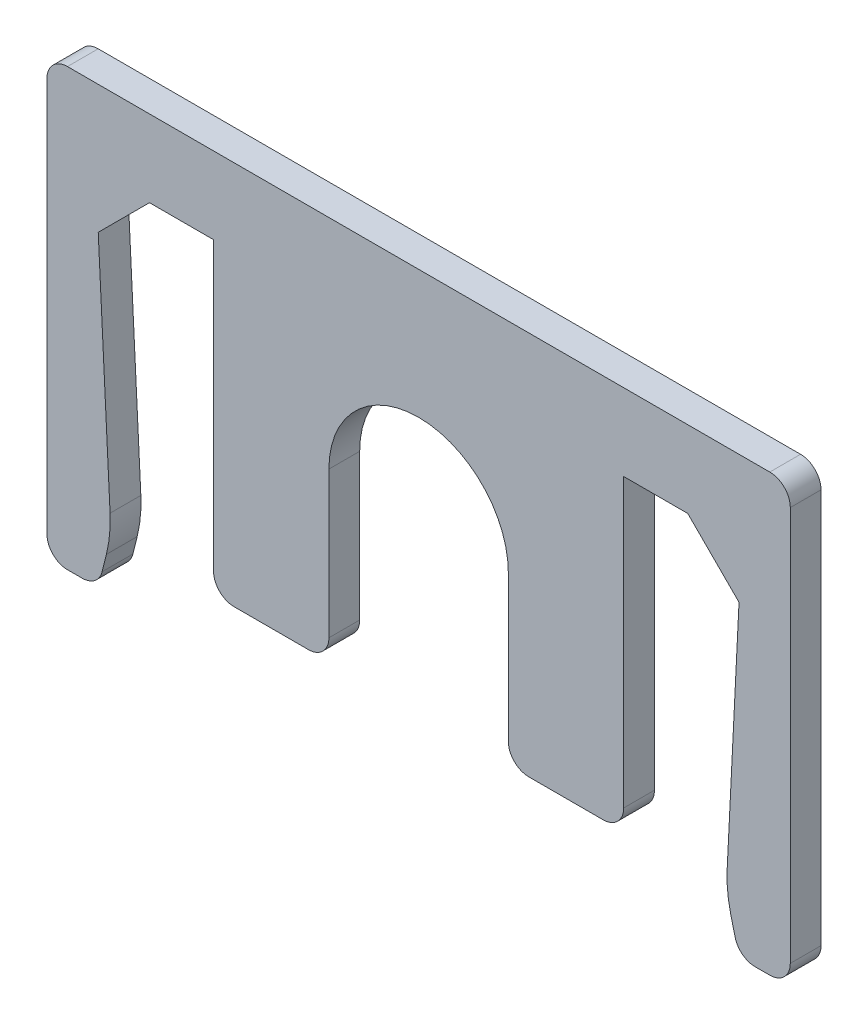
from build123d import *

# Parameters (mm, degrees)
BOSS_EXTRUDE1_DEPTH = 1.2
FILLET1_R           = 5
FILLET2_R           = 0.8


with BuildPart() as part:
    # Sketch1 → Boss-Extrude1 (new body)
    with BuildSketch(Plane.XY):
        with BuildLine():
            Line((-10.5, 0), (-12.5, -2))
            Line((-12.5, -2), (-12, -12))
            Line((-12, -12), (-12.5, -14))
            Line((-12.5, -14), (-14.5, -14))
            Line((-14.5, -14), (-14.5, 3))
            Line((-14.5, 3), (-12.5, 3))
            Line((-12.5, 3), (12.5, 3))
            Line((12.5, 3), (14.5, 3))
            Line((14.5, 3), (14.5, -14))
            Line((14.5, -14), (12.5, -14))
            Line((12.5, -14), (12, -12))
            Line((12, -12), (12.5, -2))
            Line((12.5, -2), (10.5, 0))
            Line((10.5, 0), (8, 0))
            Line((8, 0), (8, -12))
            Line((8, -12), (3.5, -12))
            Line((3.5, -12), (3.5, -5.5))
            ThreePointArc((3.5, -5.5), (0, -2), (-3.5, -5.5))
            Line((-3.5, -5.5), (-3.5, -12))
            Line((-3.5, -12), (-8, -12))
            Line((-8, -12), (-8, 0))
            Line((-8, 0), (-10.5, 0))
        make_face()
    extrude(amount=BOSS_EXTRUDE1_DEPTH)

    # Fillet1
    fillet1_edges = [part.edges().sort_by_distance(p)[0] for p in [
        (-12, -12, 0.6),
        (12, -12, 0.6),
    ]]
    fillet(fillet1_edges, radius=FILLET1_R)

    # Fillet2
    fillet2_edges = [part.edges().sort_by_distance(p)[0] for p in [
        (-12.5, -14, 0.6),
        (-14.5, -14, 0.6),
        (-14.5, 3, 0.6),
        (14.5, 3, 0.6),
        (14.5, -14, 0.6),
        (12.5, -14, 0.6),
        (8, -12, 0.6),
        (3.5, -12, 0.6),
        (-3.5, -12, 0.6),
        (-8, -12, 0.6),
    ]]
    fillet(fillet2_edges, radius=FILLET2_R)


solid = part.part
